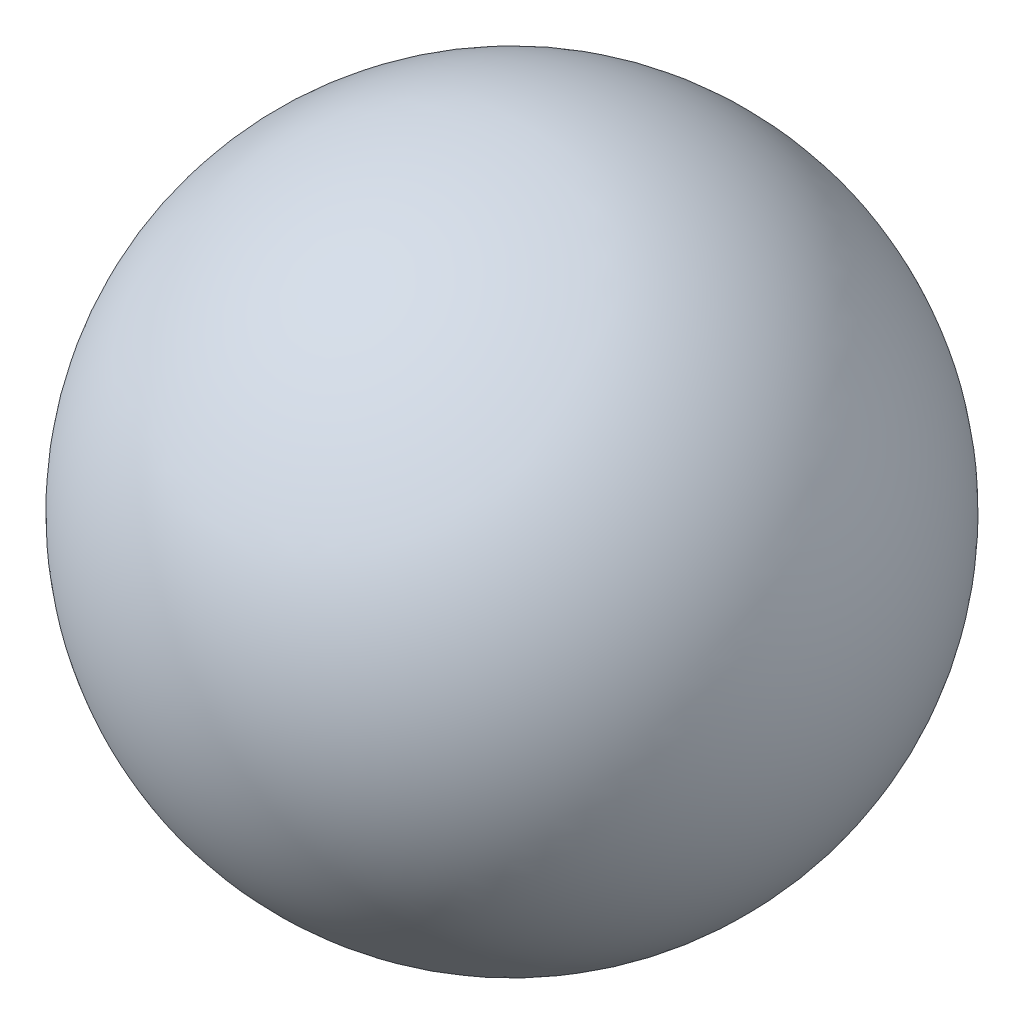
from build123d import *


with BuildPart() as part:
    # 草图1 one side → 旋转2 (revolve)
    with BuildSketch(Plane(origin=(0, 0, 0), x_dir=(1, 0, 0), z_dir=(0, 1, 0))):
        with BuildLine():
            ThreePointArc((0, -0.5), (0.353553391, -0.353553391), (0.5, 0))
            ThreePointArc((0.5, 0), (0.353553391, 0.353553391), (0, 0.5))
            Line((0, 0.5), (0, -0.5))
        make_face()
    revolve(axis=Axis((0, 0, -0.867549297), (0, 0, 1)))


solid = part.part
